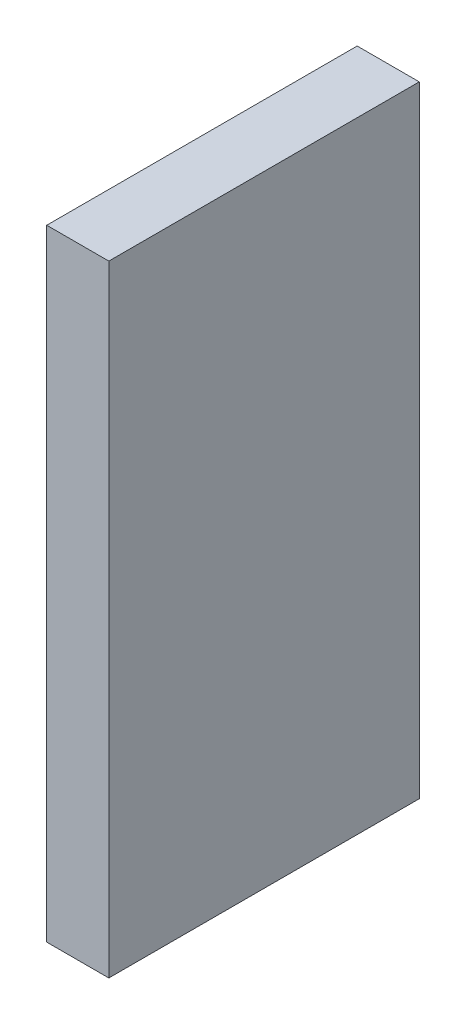
from build123d import *

# Parameters (mm, degrees)
CROQUIS1_W              = 60
CROQUIS1_H              = 120
SALIENTE_EXTRUIR1_DEPTH = 12


with BuildPart() as part:
    # Croquis1 → Saliente-Extruir1 (new body)
    with BuildSketch(Plane(origin=(0, 0, 0), x_dir=(0, 0, -1), z_dir=(1, 0, 0))):
        Rectangle(CROQUIS1_W, CROQUIS1_H)
    extrude(amount=SALIENTE_EXTRUIR1_DEPTH)


solid = part.part
